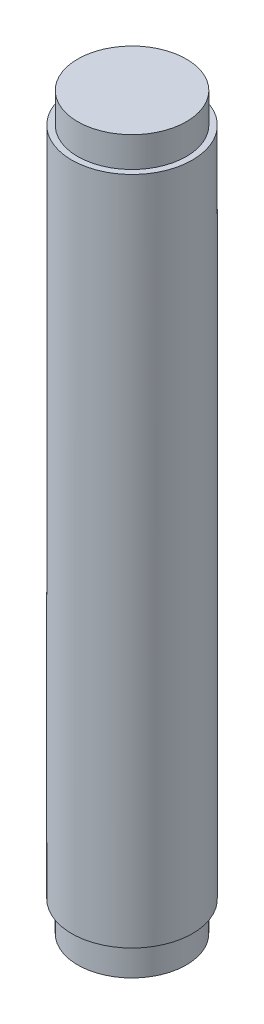
from build123d import *

# Parameters (mm, degrees)
SKETCH1_R           = 5
BOSS_EXTRUDE1_DEPTH = 60.5
SKETCH24_R          = 5
SKETCH24_R_2        = 4.5
CUT_EXTRUDE3_DEPTH  = 2.5
SKETCH25_R          = 5
SKETCH25_R_2        = 4.5
CUT_EXTRUDE4_DEPTH  = 2.5


with BuildPart() as part:
    # Sketch1 → Boss-Extrude1 (new body)
    with BuildSketch(Plane(origin=(0, 0, 0), x_dir=(1, 0, 0), z_dir=(0, 1, 0))):
        Circle(SKETCH1_R)
    extrude(amount=BOSS_EXTRUDE1_DEPTH)

    # Sketch24 → Cut-Extrude3 (cut)
    with BuildSketch(Plane(origin=(0, 0, 0), x_dir=(-1, 0, 0), z_dir=(0, -1, 0))):
        Circle(SKETCH24_R)
        Circle(SKETCH24_R_2, mode=Mode.SUBTRACT)
    extrude(amount=-CUT_EXTRUDE3_DEPTH, mode=Mode.SUBTRACT)

    # Sketch25 → Cut-Extrude4 (cut)
    with BuildSketch(Plane(origin=(0, 60.5, 0), x_dir=(1, 0, 0), z_dir=(0, 1, 0))):
        Circle(SKETCH25_R)
        Circle(SKETCH25_R_2, mode=Mode.SUBTRACT)
    extrude(amount=-CUT_EXTRUDE4_DEPTH, mode=Mode.SUBTRACT)


solid = part.part
